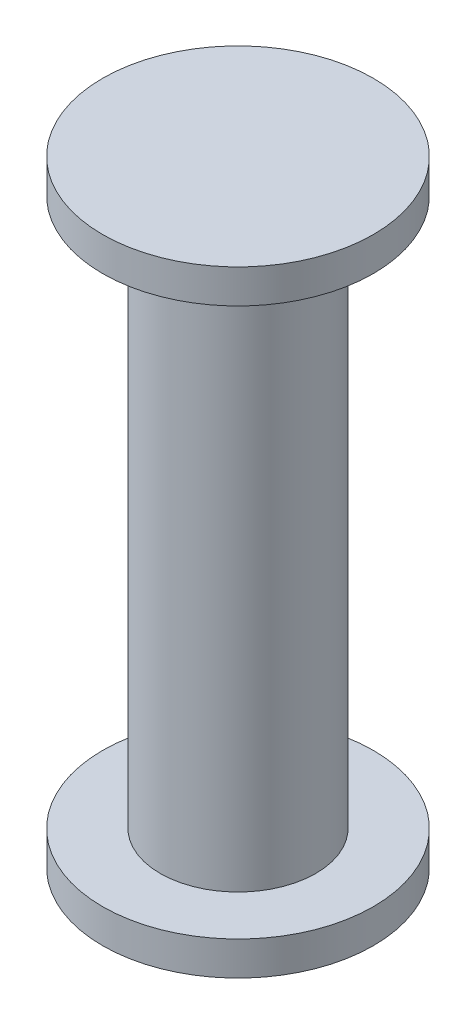
from build123d import *

# Parameters (mm, degrees)
SKETCH1_R           = 2.3
BOSS_EXTRUDE1_DEPTH = 18.2
BOSS_EXTRUDE2_START = 9.1
SKETCH2_R           = 4
SKETCH2_R_2         = 2.3
BOSS_EXTRUDE2_DEPTH = 1
BOSS_EXTRUDE3_START = -9.1
SKETCH2_3_R         = 4
SKETCH2_3_R_2       = 2.3
BOSS_EXTRUDE3_DEPTH = 1


with BuildPart() as part:
    # Sketch1 → Boss-Extrude1 (new body)
    with BuildSketch(Plane(origin=(0, 0, 0), x_dir=(1, 0, 0), z_dir=(0, 1, 0))):
        Circle(SKETCH1_R)
    extrude(amount=BOSS_EXTRUDE1_DEPTH)

    # Sketch2 → Boss-Extrude2 (add)
    with BuildSketch(Plane(origin=(0, 9.1, 0), x_dir=(1, 0, 0), z_dir=(0, 1, 0)).offset(BOSS_EXTRUDE2_START)):
        Circle(SKETCH2_R)
        Circle(SKETCH2_R_2, mode=Mode.SUBTRACT)
    extrude(amount=-BOSS_EXTRUDE2_DEPTH)

    # Sketch2_3 → Boss-Extrude3 (add)
    with BuildSketch(Plane(origin=(0, 9.1, 0), x_dir=(1, 0, 0), z_dir=(0, 1, 0)).offset(BOSS_EXTRUDE3_START)):
        Circle(SKETCH2_3_R)
        Circle(SKETCH2_3_R_2, mode=Mode.SUBTRACT)
    extrude(amount=BOSS_EXTRUDE3_DEPTH)


solid = part.part
